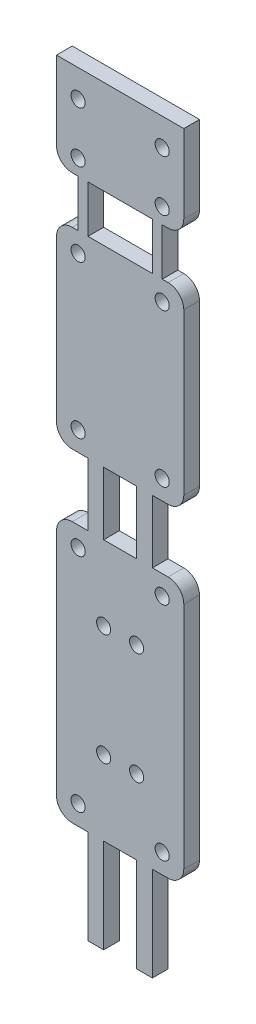
from build123d import *

# Parameters (mm, degrees)
SKETCH1_R           = 0.9
SKETCH1_W           = 4.2
SKETCH1_H           = 8
SKETCH1_W_2         = 8.2
SKETCH1_H_2         = 6
BOSS_EXTRUDE1_DEPTH = 2


with BuildPart() as part:
    # Sketch1 → Boss-Extrude1 (new body)
    with BuildSketch(Plane.XY):
        with BuildLine():
            Line((16.2, 109.64), (0, 109.64))
            Line((0, 109.64), (0, 99.66))
            ThreePointArc((0, 99.66), (0.585786438, 98.245786438), (2, 97.66))
            Line((2, 97.66), (2.75, 97.66))
            Line((2.75, 97.66), (2.75, 91.66))
            Line((2.75, 91.66), (2, 91.66))
            ThreePointArc((2, 91.66), (0.585786438, 91.074213562), (0, 89.66))
            Line((0, 89.66), (0, 69.21))
            ThreePointArc((0, 69.21), (0.585786438, 67.795786438), (2, 67.21))
            Line((2, 67.21), (4, 67.21))
            Line((4, 67.21), (4, 59.21))
            Line((4, 59.21), (2, 59.21))
            ThreePointArc((2, 59.21), (0.585786438, 58.624213562), (0, 57.21))
            Line((0, 57.21), (0, 28))
            ThreePointArc((0, 28), (0.585786438, 26.585786438), (2, 26))
            Line((2, 26), (4, 26))
            Line((4, 26), (4, 14))
            Line((4, 14), (6, 14))
            Line((6, 14), (6, 26))
            Line((6, 26), (10.2, 26))
            Line((10.2, 26), (10.2, 14))
            Line((10.2, 14), (12.2, 14))
            Line((12.2, 14), (12.2, 26))
            Line((12.2, 26), (14.2, 26))
            ThreePointArc((14.2, 26), (15.614213562, 26.585786438), (16.2, 28))
            Line((16.2, 28), (16.2, 57.21))
            ThreePointArc((16.2, 57.21), (15.614213562, 58.624213562), (14.2, 59.21))
            Line((14.2, 59.21), (12.2, 59.21))
            Line((12.2, 59.21), (12.2, 67.21))
            Line((12.2, 67.21), (14.2, 67.21))
            ThreePointArc((14.2, 67.21), (15.614213562, 67.795786438), (16.2, 69.21))
            Line((16.2, 69.21), (16.2, 89.66))
            ThreePointArc((16.2, 89.66), (15.614213562, 91.074213562), (14.2, 91.66))
            Line((14.2, 91.66), (13.45, 91.66))
            Line((13.45, 91.66), (13.45, 97.66))
            Line((13.45, 97.66), (14.2, 97.66))
            ThreePointArc((14.2, 97.66), (15.614213562, 98.245786438), (16.2, 99.66))
            Line((16.2, 99.66), (16.2, 109.64))
        make_face()
        with Locations((13.45, 56.71)):
            Circle(SKETCH1_R, mode=Mode.SUBTRACT)
        with Locations((10.2, 49.71)):
            Circle(SKETCH1_R, mode=Mode.SUBTRACT)
        with Locations((13.45, 106.16)):
            Circle(SKETCH1_R, mode=Mode.SUBTRACT)
        with Locations((2.75, 99.66)):
            Circle(SKETCH1_R, mode=Mode.SUBTRACT)
        with Locations((6, 49.71)):
            Circle(SKETCH1_R, mode=Mode.SUBTRACT)
        with Locations((2.75, 28.5)):
            Circle(SKETCH1_R, mode=Mode.SUBTRACT)
        with Locations((2.75, 89.16)):
            Circle(SKETCH1_R, mode=Mode.SUBTRACT)
        with Locations((2.75, 56.71)):
            Circle(SKETCH1_R, mode=Mode.SUBTRACT)
        with Locations((13.45, 89.16)):
            Circle(SKETCH1_R, mode=Mode.SUBTRACT)
        with Locations((13.45, 99.66)):
            Circle(SKETCH1_R, mode=Mode.SUBTRACT)
        with Locations((13.45, 69.71)):
            Circle(SKETCH1_R, mode=Mode.SUBTRACT)
        with Locations((6, 35.5)):
            Circle(SKETCH1_R, mode=Mode.SUBTRACT)
        with Locations((2.75, 106.16)):
            Circle(SKETCH1_R, mode=Mode.SUBTRACT)
        with Locations((10.2, 35.5)):
            Circle(SKETCH1_R, mode=Mode.SUBTRACT)
        with Locations((2.75, 69.71)):
            Circle(SKETCH1_R, mode=Mode.SUBTRACT)
        with Locations((13.45, 28.5)):
            Circle(SKETCH1_R, mode=Mode.SUBTRACT)
        with Locations((8.1, 63.21)):
            Rectangle(SKETCH1_W, SKETCH1_H, mode=Mode.SUBTRACT)
        with Locations((8.1, 94.66)):
            Rectangle(SKETCH1_W_2, SKETCH1_H_2, mode=Mode.SUBTRACT)
    extrude(amount=BOSS_EXTRUDE1_DEPTH)


solid = part.part
